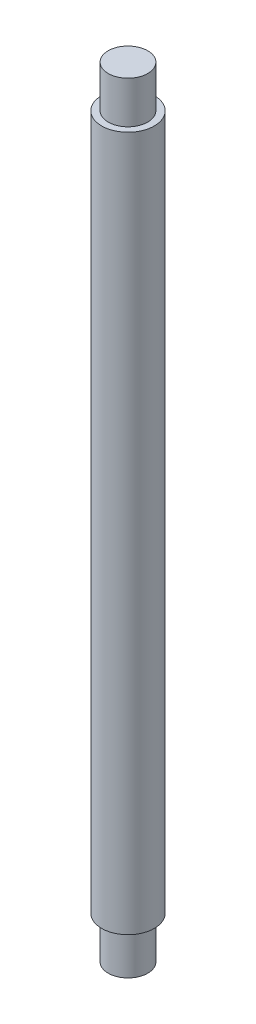
from build123d import *

# Parameters (mm, degrees)
CROQUIS1_R              = 2.5
SALIENTE_EXTRUIR1_DEPTH = 66
CROQUIS2_R              = 1.875
SALIENTE_EXTRUIR2_DEPTH = 4
CROQUIS3_R              = 1.875
SALIENTE_EXTRUIR3_DEPTH = 4


with BuildPart() as part:
    # Croquis1 → Saliente-Extruir1 (new body)
    with BuildSketch(Plane(origin=(0, 0, 0), x_dir=(1, 0, 0), z_dir=(0, 1, 0))):
        Circle(CROQUIS1_R)
    extrude(amount=SALIENTE_EXTRUIR1_DEPTH)

    # Croquis2 → Saliente-Extruir2 (add)
    with BuildSketch(Plane(origin=(0, 66, 0), x_dir=(1, 0, 0), z_dir=(0, 1, 0))):
        Circle(CROQUIS2_R)
    extrude(amount=SALIENTE_EXTRUIR2_DEPTH)

    # Croquis3 → Saliente-Extruir3 (add)
    with BuildSketch(Plane.XZ):
        Circle(CROQUIS3_R)
    extrude(amount=SALIENTE_EXTRUIR3_DEPTH)


solid = part.part
